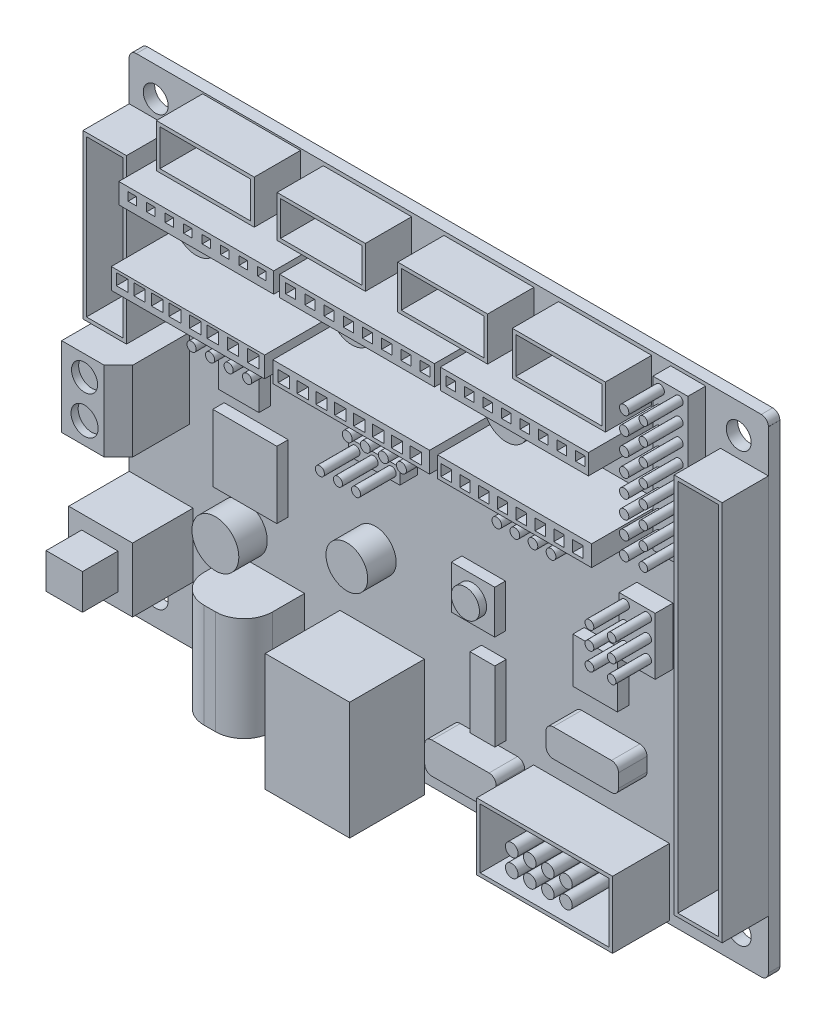
from build123d import *

# Parameters (mm, degrees)
BLACK_SMD_W             = 5.667528789
BLACK_SMD_H             = 6.353116949
BOSS_EXTRU_2_DEPTH      = 1.6
BLACK_SMD_W_2           = 9.004057835
BLACK_SMD_H_2           = 9.41541073
BOSS_EXTRU_2_2_DEPTH    = 1.6
BLACK_SMD_W_3           = 6.261705195
BOSS_EXTRU_2_3_DEPTH    = 1.6
BLACK_SMD_W_4           = 3.473646677
BLACK_SMD_H_3           = 9.872469503
BOSS_EXTRU_2_4_DEPTH    = 1.6
CAPA_CRYSTALS_R         = 3.185682442
BOSS_EXTRU_3_DEPTH      = 4
CAPA_CRYSTALS_R_2       = 3.107590138
BOSS_EXTRU_3_2_DEPTH    = 4
CAPA_CRYSTALS_R_3       = 3.145601867
BOSS_EXTRU_3_3_DEPTH    = 4
CAPA_CRYSTALS_R_4       = 2.932098197
BOSS_EXTRU_3_4_DEPTH    = 4
CAPA_CRYSTALS_R_5       = 3.296265694
BOSS_EXTRU_3_5_DEPTH    = 4
BOSS_EXTRU_3_6_DEPTH    = 4
BOSS_EXTRU_3_7_DEPTH    = 4
YELLOW_MALES_W          = 4.914957964
YELLOW_MALES_H          = 21.157358111
BOSS_EXTRU_4_DEPTH      = 2.5
YELLOW_MALES_W_2        = 5.072677352
YELLOW_MALES_H_2        = 8.037692987
BOSS_EXTRU_4_2_DEPTH    = 2.5
YELLOW_MALES_W_3        = 10.02137058
YELLOW_MALES_H_3        = 2.383305897
BOSS_EXTRU_4_3_DEPTH    = 2.5
YELLOW_MALES_W_4        = 9.80555218
BOSS_EXTRU_4_4_DEPTH    = 2.5
YELLOW_MALES_W_5        = 9.889772519
BOSS_EXTRU_4_5_DEPTH    = 2.5
YELLOW_MALES_W_6        = 7.186380027
YELLOW_MALES_H_4        = 2.19056063
BOSS_EXTRU_4_6_DEPTH    = 2.5
BLACKHEADERS_W          = 19.09327542
BLACKHEADERS_H          = 9.384830291
BOSS_EXTRU_5_DEPTH      = 8
BLUE_CONNECTOR_W        = 7.979000373
BLUE_CONNECTOR_H        = 11.177478971
BOSS_EXTRU_6_DEPTH      = 10
YELLOW_FEMALES_W        = 13.758897452
YELLOW_FEMALES_H        = 6.10412624
BOSS_EXTRU_7_DEPTH      = 6.5
YELLOW_FEMALES_W_2      = 12.405159778
YELLOW_FEMALES_H_2      = 5.833378705
BOSS_EXTRU_7_2_DEPTH    = 6.5
YELLOW_FEMALES_W_3      = 12.626680488
YELLOW_FEMALES_H_3      = 6.096742216
BOSS_EXTRU_7_3_DEPTH    = 6.5
YELLOW_FEMALES_W_4      = 13.079739121
BOSS_EXTRU_7_4_DEPTH    = 6.5
YELLOW_FEMALES_W_5      = 6.119428218
YELLOW_FEMALES_H_4      = 22.94160465
BOSS_EXTRU_7_5_DEPTH    = 6.5
YELLOW_FEMALES_W_6      = 6.736078406
YELLOW_FEMALES_H_5      = 53.569497278
BOSS_EXTRU_7_6_DEPTH    = 6.5
POWER12V_W              = 9.630174402
POWER12V_H              = 14.593768451
BOSS_EXTRU_8_DEPTH      = 8.5
USBPLUG_W               = 11.865628118
USBPLUG_H               = 16.535326927
BOSS_EXTRU_9_DEPTH      = 10.5
BUTTON_W                = 8.967148954
BUTTON_H                = 9.006388335
BOSS_EXTRU_10_DEPTH     = 8.5
RESET_W                 = 6.108615354
RESET_H                 = 6.080070422
BOSS_EXTRU_11_DEPTH     = 1.5
BOUTROUGE_R             = 1.981766693
BOSS_EXTRU_12_DEPTH     = 1
BOUTONON_W              = 5.108667304
BOUTONON_H              = 4.961772718
BOSS_EXTRU_13_DEPTH     = 5
CHANFREIN1_SIZE         = 2
CONG_1_R                = 4
ESQUISSE14_R            = 2.872316095
ENL_V_MAT_EXTRU_1_DEPTH = 10
ESQUISSE15_W            = 4.536879196
ESQUISSE15_H            = 2.837024223
ENL_V_MAT_EXTRU_2_DEPTH = 10
COQUE1_T                = -0.5
COQUE2_T                = -0.5
COQUE3_T                = -0.5
COQUE4_T                = -0.5
COQUE5_T                = -0.5
COQUE6_T                = -0.5
COQUE7_T                = -0.5
ESQUISSE16_R            = 1.832241223
ESQUISSE16_R_2          = 1.902205742
ENL_V_MAT_EXTRU_3_DEPTH = 1
CONNECTURES_JAUNES_W    = 21.766129974
CONNECTURES_JAUNES_H    = 2.845572038
CONNECTURES_JAUNES_W_2  = 1.144667962
CONNECTURES_JAUNES_H_2  = 1.160348345
BOSS_EXTRU_14_DEPTH     = 10
CONNECTURES_JAUNES_W_3  = 21.751237847
CONNECTURES_JAUNES_W_4  = 1.412281688
CONNECTURES_JAUNES_H_3  = 1.368226061
BOSS_EXTRU_14_2_DEPTH   = 10
CONNECTURES_JAUNES_W_5  = 20.809255106
CONNECTURES_JAUNES_W_6  = 1.305396378
CONNECTURES_JAUNES_H_4  = 1.311416644
BOSS_EXTRU_14_3_DEPTH   = 10
CONNECTEURS_NOIRS_W     = 21.542495223
CONNECTEURS_NOIRS_H     = 2.89995128
CONNECTEURS_NOIRS_W_2   = 1.623681217
CONNECTEURS_NOIRS_H_2   = 1.607525185
CONNECTEURS_NOIRS_W_3   = 1.591369153
CONNECTEURS_NOIRS_W_4   = 1.607525185
CONNECTEURS_NOIRS_W_5   = 1.679612214
CONNECTEURS_NOIRS_H_3   = 1.644637005
CONNECTEURS_NOIRS_W_6   = 1.594783313
CONNECTEURS_NOIRS_W_7   = 1.623059613
CONNECTEURS_NOIRS_W_8   = 1.570532536
CONNECTEURS_NOIRS_H_4   = 1.602694416
CONNECTEURS_NOIRS_W_9   = 1.616724668
CONNECTEURS_NOIRS_H_5   = 1.718717031
BOSS_EXTRU_15_DEPTH     = 10
CONNECTEURS_NOIRS_W_10  = 22.022715309
CONNECTEURS_NOIRS_W_11  = 1.593377301
CONNECTEURS_NOIRS_H_6   = 1.582156334
BOSS_EXTRU_15_2_DEPTH   = 10
CONNECTEURS_NOIRS_W_12  = 21.644304887
CONNECTEURS_NOIRS_W_13  = 1.447331161
BOSS_EXTRU_15_3_DEPTH   = 10
MALE_POINS_R            = 0.643851122
MALE_POINS_R_2          = 0.696264163
MALE_POINS_R_3          = 0.636731824
MALE_POINS_R_4          = 0.681329033
MALE_POINS_R_5          = 0.655895969
MALE_POINS_R_6          = 0.599442367
MALE_POINS_R_7          = 0.619190014
MALE_POINS_R_8          = 0.60345103
BOSS_EXTRU_16_DEPTH     = 5
ESQUISSE20_R            = 0.886471356
BOSS_EXTRU_17_DEPTH     = 8
ESQUISSE1_R             = 1.75
BOSS_EXTRU_18_DEPTH     = 1.6
ESQUISSE21_W            = 1.6
ESQUISSE21_H            = 66.466866995
BOSS_EXTRU_19_DEPTH     = 0.01
ESQUISSE22_W            = 1.6
ESQUISSE22_H            = 66.466866995
BOSS_EXTRU_20_DEPTH     = 0.01


with BuildPart() as part:
    # black smd → Boss.-Extru.2 (new body)
    with BuildSketch(Plane.XY):
        with Locations((27.451835352, 92.668727708)):
            Rectangle(BLACK_SMD_W, BLACK_SMD_H)
    extrude(amount=BOSS_EXTRU_2_DEPTH)



with BuildPart() as body_2:
    # black smd → Boss.-Extru.2 2 (new body)
    with BuildSketch(Plane.XY):
        with Locations((28.297394083, 81.950699473)):
            Rectangle(BLACK_SMD_W_2, BLACK_SMD_H_2)
    extrude(amount=BOSS_EXTRU_2_2_DEPTH)


with BuildPart() as body_3:
    # black smd → Boss.-Extru.2 3 (new body)
    with BuildSketch(Plane.XY):
        with Locations((77.522623968, 81.425081884)):
            Rectangle(BLACK_SMD_W_3, BLACK_SMD_H)
    extrude(amount=BOSS_EXTRU_2_3_DEPTH)


with BuildPart() as body_4:
    # black smd → Boss.-Extru.2 4 (new body)
    with BuildSketch(Plane.XY):
        with Locations((61.685537474, 70.295700754)):
            Rectangle(BLACK_SMD_W_4, BLACK_SMD_H_3)
    extrude(amount=BOSS_EXTRU_2_4_DEPTH)


with BuildPart() as body_5:
    # capa-crystals → Boss.-Extru.3 (new body)
    with BuildSketch(Plane.XY):
        with Locations((23.864549463, 109.798281788)):
            Circle(CAPA_CRYSTALS_R)
    extrude(amount=BOSS_EXTRU_3_DEPTH)


with BuildPart() as body_6:
    # capa-crystals → Boss.-Extru.3 2 (new body)
    with BuildSketch(Plane.XY):
        with Locations((45.731701556, 109.764509907)):
            Circle(CAPA_CRYSTALS_R_2)
    extrude(amount=BOSS_EXTRU_3_2_DEPTH)


with BuildPart() as body_7:
    # capa-crystals → Boss.-Extru.3 3 (new body)
    with BuildSketch(Plane.XY):
        with Locations((67.426141208, 108.850187956)):
            Circle(CAPA_CRYSTALS_R_3)
    extrude(amount=BOSS_EXTRU_3_3_DEPTH)


with BuildPart() as body_8:
    # capa-crystals → Boss.-Extru.3 4 (new body)
    with BuildSketch(Plane.XY):
        with Locations((45.03448566, 79.310789046)):
            Circle(CAPA_CRYSTALS_R_4)
    extrude(amount=BOSS_EXTRU_3_4_DEPTH)


with BuildPart() as body_9:
    # capa-crystals → Boss.-Extru.3 5 (new body)
    with BuildSketch(Plane.XY):
        with Locations((26.561536765, 72.880879708)):
            Circle(CAPA_CRYSTALS_R_5)
    extrude(amount=BOSS_EXTRU_3_5_DEPTH)


with BuildPart() as body_10:
    # capa-crystals → Boss.-Extru.3 6 (new body)
    with BuildSketch(Plane.XY):
        with BuildLine():
            Line((74.029880501, 74.337328349), (82.213679809, 74.337328349))
            ThreePointArc((82.213679809, 74.337328349), (82.92078659, 74.04443513), (83.213679809, 73.337328349))
            Line((83.213679809, 73.337328349), (83.213679809, 71.430452614))
            ThreePointArc((83.213679809, 71.430452614), (82.92078659, 70.723345833), (82.213679809, 70.430452614))
            Line((82.213679809, 70.430452614), (74.029880501, 70.430452614))
            ThreePointArc((74.029880501, 70.430452614), (73.32277372, 70.723345833), (73.029880501, 71.430452614))
            Line((73.029880501, 71.430452614), (73.029880501, 73.337328349))
            ThreePointArc((73.029880501, 73.337328349), (73.32277372, 74.04443513), (74.029880501, 74.337328349))
        make_face()
    extrude(amount=BOSS_EXTRU_3_6_DEPTH)


with BuildPart() as body_11:
    # capa-crystals → Boss.-Extru.3 7 (new body)
    with BuildSketch(Plane.XY):
        with BuildLine():
            Line((56.976645659, 64.209077037), (65.012316977, 64.209077037))
            ThreePointArc((65.012316977, 64.209077037), (65.719423758, 63.916183818), (66.012316977, 63.209077037))
            Line((66.012316977, 63.209077037), (66.012316977, 60.802269336))
            ThreePointArc((66.012316977, 60.802269336), (65.719423758, 60.095162555), (65.012316977, 59.802269336))
            Line((65.012316977, 59.802269336), (56.976645659, 59.802269336))
            ThreePointArc((56.976645659, 59.802269336), (56.269538877, 60.095162555), (55.976645659, 60.802269336))
            Line((55.976645659, 60.802269336), (55.976645659, 63.209077037))
            ThreePointArc((55.976645659, 63.209077037), (56.269538877, 63.916183818), (56.976645659, 64.209077037))
        make_face()
    extrude(amount=BOSS_EXTRU_3_7_DEPTH)


with BuildPart() as body_12:
    # yellow males → Boss.-Extru.4 (new body)
    with BuildSketch(Plane.XY):
        with Locations((88.999549893, 111.93581949)):
            Rectangle(YELLOW_MALES_W, YELLOW_MALES_H)
    extrude(amount=BOSS_EXTRU_4_DEPTH)



with BuildPart() as body_13:
    # yellow males → Boss.-Extru.4 2 (new body)
    with BuildSketch(Plane.XY):
        with Locations((84.324792683, 89.789654597)):
            Rectangle(YELLOW_MALES_W_2, YELLOW_MALES_H_2)
    extrude(amount=BOSS_EXTRU_4_2_DEPTH)


with BuildPart() as body_14:
    # yellow males → Boss.-Extru.4 3 (new body)
    with BuildSketch(Plane.XY):
        with Locations((30.694945941, 98.746631162)):
            Rectangle(YELLOW_MALES_W_3, YELLOW_MALES_H_3)
    extrude(amount=BOSS_EXTRU_4_3_DEPTH)


with BuildPart() as body_15:
    # yellow males → Boss.-Extru.4 4 (new body)
    with BuildSketch(Plane.XY):
        with Locations((52.352649633, 98.746631162)):
            Rectangle(YELLOW_MALES_W_4, YELLOW_MALES_H_3)
    extrude(amount=BOSS_EXTRU_4_4_DEPTH)


with BuildPart() as body_16:
    # yellow males → Boss.-Extru.4 5 (new body)
    with BuildSketch(Plane.XY):
        with Locations((73.557762357, 98.746631162)):
            Rectangle(YELLOW_MALES_W_5, YELLOW_MALES_H_3)
    extrude(amount=BOSS_EXTRU_4_5_DEPTH)


with BuildPart() as body_17:
    # yellow males → Boss.-Extru.4 6 (new body)
    with BuildSketch(Plane.XY):
        with Locations((47.382493908, 92.554802146)):
            Rectangle(YELLOW_MALES_W_6, YELLOW_MALES_H_4)
    extrude(amount=BOSS_EXTRU_4_6_DEPTH)


with BuildPart() as body_18:
    # blackheaders → Boss.-Extru.5 (new body)
    with BuildSketch(Plane.XY):
        with Locations((76.827722943, 59.625791726)):
            Rectangle(BLACKHEADERS_W, BLACKHEADERS_H)
    extrude(amount=BOSS_EXTRU_5_DEPTH)

    # Coque6
    coque6_openings = [body_18.faces().sort_by_distance(p)[0] for p in [
        (76.827722943, 59.625791725, 8),
    ]]
    offset(amount=COQUE6_T, openings=coque6_openings, kind=Kind.INTERSECTION)

    # Esquisse20 → Boss.-Extru.17 (add)
    with BuildSketch(Plane(origin=(1.991400951, -0.772175879, 0.5), x_dir=(1, 0, 0), z_dir=(0, 0, 1))):
        with Locations((70.711902777, 61.723200827)):
            Circle(ESQUISSE20_R)
        with Locations((73.251902777, 61.723200827)):
            Circle(ESQUISSE20_R)
        with Locations((75.791902777, 61.723200827)):
            Circle(ESQUISSE20_R)
        with Locations((78.331902777, 61.723200827)):
            Circle(ESQUISSE20_R)
        with Locations((73.251902777, 59.183200827)):
            Circle(ESQUISSE20_R)
        with Locations((75.791902777, 59.183200827)):
            Circle(ESQUISSE20_R)
        with Locations((78.331902777, 59.183200827)):
            Circle(ESQUISSE20_R)
        with Locations((70.711902777, 59.183200827)):
            Circle(ESQUISSE20_R)
    extrude(amount=BOSS_EXTRU_17_DEPTH)


with BuildPart() as body_19:
    # blue connector → Boss.-Extru.6 (new body)
    with BuildSketch(Plane.XY):
        with Locations((14.954034151, 87.207277797)):
            Rectangle(BLUE_CONNECTOR_W, BLUE_CONNECTOR_H)
    extrude(amount=BOSS_EXTRU_6_DEPTH)

    # Chanfrein1
    chanfrein1_edges = [body_19.edges().sort_by_distance(p)[0] for p in [
        (18.943534337, 87.207277796, 10),
    ]]
    chamfer(chanfrein1_edges, length=CHANFREIN1_SIZE)

    # Esquisse16 → Enlèv. mat.-Extru.3 (cut)
    with BuildSketch(Plane.XY.offset(10)):
        with Locations((14.182289889, 89.945307425)):
            Circle(ESQUISSE16_R)
        with Locations((14.182289889, 84.657102292)):
            Circle(ESQUISSE16_R_2)
    extrude(amount=-ENL_V_MAT_EXTRU_3_DEPTH, mode=Mode.SUBTRACT)


with BuildPart() as body_20:
    # yellow females → Boss.-Extru.7 (new body)
    with BuildSketch(Plane.XY):
        with Locations((27.650264608, 119.67670561)):
            Rectangle(YELLOW_FEMALES_W, YELLOW_FEMALES_H)
    extrude(amount=BOSS_EXTRU_7_DEPTH)

    # Coque1
    coque1_openings = [body_20.faces().sort_by_distance(p)[0] for p in [
        (27.650264608, 119.67670561, 6.5),
    ]]
    offset(amount=COQUE1_T, openings=coque1_openings, kind=Kind.INTERSECTION)


with BuildPart() as body_21:
    # yellow females → Boss.-Extru.7 2 (new body)
    with BuildSketch(Plane.XY):
        with Locations((43.932036817, 119.541331842)):
            Rectangle(YELLOW_FEMALES_W_2, YELLOW_FEMALES_H_2)
    extrude(amount=BOSS_EXTRU_7_2_DEPTH)

    # Coque2
    coque2_openings = [body_21.faces().sort_by_distance(p)[0] for p in [
        (43.932036817, 119.541331842, 6.5),
    ]]
    offset(amount=COQUE2_T, openings=coque2_openings, kind=Kind.INTERSECTION)


with BuildPart() as body_22:
    # yellow females → Boss.-Extru.7 3 (new body)
    with BuildSketch(Plane.XY):
        with Locations((61.001438217, 119.409650087)):
            Rectangle(YELLOW_FEMALES_W_3, YELLOW_FEMALES_H_3)
    extrude(amount=BOSS_EXTRU_7_3_DEPTH)

    # Coque3
    coque3_openings = [body_22.faces().sort_by_distance(p)[0] for p in [
        (61.001438217, 119.409650087, 6.5),
    ]]
    offset(amount=COQUE3_T, openings=coque3_openings, kind=Kind.INTERSECTION)


with BuildPart() as body_23:
    # yellow females → Boss.-Extru.7 4 (new body)
    with BuildSketch(Plane.XY):
        with Locations((77.324717378, 119.409650087)):
            Rectangle(YELLOW_FEMALES_W_4, YELLOW_FEMALES_H_3)
    extrude(amount=BOSS_EXTRU_7_4_DEPTH)

    # Coque4
    coque4_openings = [body_23.faces().sort_by_distance(p)[0] for p in [
        (77.324717378, 119.409650087, 6.5),
    ]]
    offset(amount=COQUE4_T, openings=coque4_openings, kind=Kind.INTERSECTION)


with BuildPart() as body_24:
    # yellow females → Boss.-Extru.7 5 (new body)
    with BuildSketch(Plane.XY):
        with Locations((13.512656055, 104.890476654)):
            Rectangle(YELLOW_FEMALES_W_5, YELLOW_FEMALES_H_4)
    extrude(amount=BOSS_EXTRU_7_5_DEPTH)

    # Coque7
    coque7_openings = [body_24.faces().sort_by_distance(p)[0] for p in [
        (13.512656055, 104.890476654, 6.5),
    ]]
    offset(amount=COQUE7_T, openings=coque7_openings, kind=Kind.INTERSECTION)


with BuildPart() as body_25:
    # yellow females → Boss.-Extru.7 6 (new body)
    with BuildSketch(Plane.XY):
        with Locations((96.907395701, 89.199249655)):
            Rectangle(YELLOW_FEMALES_W_6, YELLOW_FEMALES_H_5)
    extrude(amount=BOSS_EXTRU_7_6_DEPTH)

    # Coque5
    coque5_openings = [body_25.faces().sort_by_distance(p)[0] for p in [
        (96.907395701, 89.199249655, 6.5),
    ]]
    offset(amount=COQUE5_T, openings=coque5_openings, kind=Kind.INTERSECTION)


with BuildPart() as body_26:
    # power12v → Boss.-Extru.8 (new body)
    with BuildSketch(Plane.XY):
        with Locations((30.282665386, 61.805056702)):
            Rectangle(POWER12V_W, POWER12V_H)
    extrude(amount=BOSS_EXTRU_8_DEPTH)

    # Congé1
    cong_1_edges = [body_26.edges().sort_by_distance(p)[0] for p in [
        (35.097752587, 61.805056702, 8.5),
        (25.467578185, 61.805056702, 8.5),
    ]]
    fillet(cong_1_edges, radius=CONG_1_R)

    # Esquisse14 → Enlèv. mat.-Extru.1 (cut)
    with BuildSketch(Plane.XZ.offset(-54.508172476)):
        with Locations((30.340408276, 4.608223464)):
            Circle(ESQUISSE14_R)
    extrude(amount=-ENL_V_MAT_EXTRU_1_DEPTH, mode=Mode.SUBTRACT)


with BuildPart() as body_27:
    # usbplug → Boss.-Extru.9 (new body)
    with BuildSketch(Plane.XY):
        with Locations((45.998146307, 61.256418237)):
            Rectangle(USBPLUG_W, USBPLUG_H)
    extrude(amount=BOSS_EXTRU_9_DEPTH)

    # Esquisse15 → Enlèv. mat.-Extru.2 (cut)
    with BuildSketch(Plane.XZ.offset(-52.988754773)):
        Polygon((43.681261857, 8.05866864), (48.218141053, 8.05866864), (50.533256363, 6.303661872), (50.533256363, 1.785452961), (41.683541388, 1.785452961), (41.683541388, 6.378343012), align=None)
        with Locations((45.949701455, 4.959830901)):
            Rectangle(ESQUISSE15_W, ESQUISSE15_H, mode=Mode.SUBTRACT)
    extrude(amount=-ENL_V_MAT_EXTRU_2_DEPTH, mode=Mode.SUBTRACT)


with BuildPart() as body_28:
    # button → Boss.-Extru.10 (new body)
    with BuildSketch(Plane.XY):
        with Locations((14.936516423, 67.138871687)):
            Rectangle(BUTTON_W, BUTTON_H)
    extrude(amount=BOSS_EXTRU_10_DEPTH)

    # boutonon → Boss.-Extru.13 (add)
    with BuildSketch(Plane.XY.offset(8.5)):
        with Locations((14.832436998, 67.17090773)):
            Rectangle(BOUTONON_W, BOUTONON_H)
    extrude(amount=BOSS_EXTRU_13_DEPTH)


with BuildPart() as body_29:
    # reset → Boss.-Extru.11 (new body)
    with BuildSketch(Plane.XY):
        with Locations((60.264292003, 81.67716215)):
            Rectangle(RESET_W, RESET_H)
    extrude(amount=BOSS_EXTRU_11_DEPTH)

    # boutrouge → Boss.-Extru.12 (add)
    with BuildSketch(Plane.XY.offset(1.5)):
        with Locations((60.191949439, 81.715872772)):
            Circle(BOUTROUGE_R)
    extrude(amount=BOSS_EXTRU_12_DEPTH)


with BuildPart() as body_30:
    # connectures jaunes → Boss.-Extru.14 (new body)
    with BuildSketch(Plane.XY):
        with Locations((29.874433173, 114.758711057)):
            Rectangle(CONNECTURES_JAUNES_W, CONNECTURES_JAUNES_H)
        with Locations((23.473914496, 115.011223112)):
            Rectangle(CONNECTURES_JAUNES_W_2, CONNECTURES_JAUNES_H_2, mode=Mode.SUBTRACT)
        with Locations((20.873914496, 115.011223112)):
            Rectangle(CONNECTURES_JAUNES_W_2, CONNECTURES_JAUNES_H_2, mode=Mode.SUBTRACT)
        with Locations((26.073914496, 115.011223112)):
            Rectangle(CONNECTURES_JAUNES_W_2, CONNECTURES_JAUNES_H_2, mode=Mode.SUBTRACT)
        with Locations((28.673914496, 115.011223112)):
            Rectangle(CONNECTURES_JAUNES_W_2, CONNECTURES_JAUNES_H_2, mode=Mode.SUBTRACT)
        with Locations((31.273914496, 115.011223112)):
            Rectangle(CONNECTURES_JAUNES_W_2, CONNECTURES_JAUNES_H_2, mode=Mode.SUBTRACT)
        with Locations((33.873914496, 115.011223112)):
            Rectangle(CONNECTURES_JAUNES_W_2, CONNECTURES_JAUNES_H_2, mode=Mode.SUBTRACT)
        with Locations((36.473914496, 115.011223112)):
            Rectangle(CONNECTURES_JAUNES_W_2, CONNECTURES_JAUNES_H_2, mode=Mode.SUBTRACT)
        with Locations((39.073914496, 115.011223112)):
            Rectangle(CONNECTURES_JAUNES_W_2, CONNECTURES_JAUNES_H_2, mode=Mode.SUBTRACT)
    extrude(amount=BOSS_EXTRU_14_DEPTH)


with BuildPart() as body_31:
    # connectures jaunes → Boss.-Extru.14 2 (new body)
    with BuildSketch(Plane.XY):
        with Locations((52.467013892, 114.758711057)):
            Rectangle(CONNECTURES_JAUNES_W_3, CONNECTURES_JAUNES_H)
        with Locations((45.840802128, 114.907284254)):
            Rectangle(CONNECTURES_JAUNES_W_4, CONNECTURES_JAUNES_H_3, mode=Mode.SUBTRACT)
        with Locations((43.140802128, 114.907284254)):
            Rectangle(CONNECTURES_JAUNES_W_4, CONNECTURES_JAUNES_H_3, mode=Mode.SUBTRACT)
        with Locations((48.540802128, 114.907284254)):
            Rectangle(CONNECTURES_JAUNES_W_4, CONNECTURES_JAUNES_H_3, mode=Mode.SUBTRACT)
        with Locations((51.240802128, 114.907284254)):
            Rectangle(CONNECTURES_JAUNES_W_4, CONNECTURES_JAUNES_H_3, mode=Mode.SUBTRACT)
        with Locations((53.940802128, 114.907284254)):
            Rectangle(CONNECTURES_JAUNES_W_4, CONNECTURES_JAUNES_H_3, mode=Mode.SUBTRACT)
        with Locations((56.640802128, 114.907284254)):
            Rectangle(CONNECTURES_JAUNES_W_4, CONNECTURES_JAUNES_H_3, mode=Mode.SUBTRACT)
        with Locations((59.340802128, 114.907284254)):
            Rectangle(CONNECTURES_JAUNES_W_4, CONNECTURES_JAUNES_H_3, mode=Mode.SUBTRACT)
        with Locations((62.040802128, 114.907284254)):
            Rectangle(CONNECTURES_JAUNES_W_4, CONNECTURES_JAUNES_H_3, mode=Mode.SUBTRACT)
    extrude(amount=BOSS_EXTRU_14_2_DEPTH)


with BuildPart() as body_32:
    # connectures jaunes → Boss.-Extru.14 3 (new body)
    with BuildSketch(Plane.XY):
        with Locations((74.575063383, 114.758711057)):
            Rectangle(CONNECTURES_JAUNES_W_5, CONNECTURES_JAUNES_H)
        with Locations((68.231383082, 114.878879545)):
            Rectangle(CONNECTURES_JAUNES_W_6, CONNECTURES_JAUNES_H_4, mode=Mode.SUBTRACT)
        with Locations((65.631383082, 114.878879545)):
            Rectangle(CONNECTURES_JAUNES_W_6, CONNECTURES_JAUNES_H_4, mode=Mode.SUBTRACT)
        with Locations((70.831383082, 114.878879545)):
            Rectangle(CONNECTURES_JAUNES_W_6, CONNECTURES_JAUNES_H_4, mode=Mode.SUBTRACT)
        with Locations((73.431383082, 114.878879545)):
            Rectangle(CONNECTURES_JAUNES_W_6, CONNECTURES_JAUNES_H_4, mode=Mode.SUBTRACT)
        with Locations((76.031383082, 114.878879545)):
            Rectangle(CONNECTURES_JAUNES_W_6, CONNECTURES_JAUNES_H_4, mode=Mode.SUBTRACT)
        with Locations((78.631383082, 114.878879545)):
            Rectangle(CONNECTURES_JAUNES_W_6, CONNECTURES_JAUNES_H_4, mode=Mode.SUBTRACT)
        with Locations((81.231383082, 114.878879545)):
            Rectangle(CONNECTURES_JAUNES_W_6, CONNECTURES_JAUNES_H_4, mode=Mode.SUBTRACT)
        with Locations((83.831383082, 114.878879545)):
            Rectangle(CONNECTURES_JAUNES_W_6, CONNECTURES_JAUNES_H_4, mode=Mode.SUBTRACT)
    extrude(amount=BOSS_EXTRU_14_3_DEPTH)


with BuildPart() as body_33:
    # connecteurs noirs → Boss.-Extru.15 (new body)
    with BuildSketch(Plane.XY):
        with Locations((28.706780425, 103.852734119)):
            Rectangle(CONNECTEURS_NOIRS_W, CONNECTEURS_NOIRS_H)
        with Locations((19.459783137, 104.119588936)):
            Rectangle(CONNECTEURS_NOIRS_W_2, CONNECTEURS_NOIRS_H_2, mode=Mode.SUBTRACT)
        with Locations((21.907421986, 104.119588936)):
            Rectangle(CONNECTEURS_NOIRS_W_3, CONNECTEURS_NOIRS_H_2, mode=Mode.SUBTRACT)
        with Locations((24.387372899, 104.119588936)):
            Rectangle(CONNECTEURS_NOIRS_W_4, CONNECTEURS_NOIRS_H_2, mode=Mode.SUBTRACT)
        with Locations((26.880477214, 104.101033026)):
            Rectangle(CONNECTEURS_NOIRS_W_5, CONNECTEURS_NOIRS_H_3, mode=Mode.SUBTRACT)
        with Locations((29.727900613, 104.101033026)):
            Rectangle(CONNECTEURS_NOIRS_W_6, CONNECTEURS_NOIRS_H_3, mode=Mode.SUBTRACT)
        with Locations((32.219042633, 104.101033026)):
            Rectangle(CONNECTEURS_NOIRS_W_7, CONNECTEURS_NOIRS_H_3, mode=Mode.SUBTRACT)
        with Locations((35.041216176, 104.080061731)):
            Rectangle(CONNECTEURS_NOIRS_W_8, CONNECTEURS_NOIRS_H_4, mode=Mode.SUBTRACT)
        with Locations((37.914366873, 104.063993013)):
            Rectangle(CONNECTEURS_NOIRS_W_9, CONNECTEURS_NOIRS_H_5, mode=Mode.SUBTRACT)
    extrude(amount=BOSS_EXTRU_15_DEPTH)


with BuildPart() as body_34:
    # connecteurs noirs → Boss.-Extru.15 2 (new body)
    with BuildSketch(Plane.XY):
        with Locations((51.652552963, 103.852734119)):
            Rectangle(CONNECTEURS_NOIRS_W_10, CONNECTEURS_NOIRS_H)
        with Locations((44.831593433, 103.697294106)):
            Rectangle(CONNECTEURS_NOIRS_W_11, CONNECTEURS_NOIRS_H_6, mode=Mode.SUBTRACT)
        with Locations((42.181593433, 103.697294106)):
            Rectangle(CONNECTEURS_NOIRS_W_11, CONNECTEURS_NOIRS_H_6, mode=Mode.SUBTRACT)
        with Locations((47.481593433, 103.697294106)):
            Rectangle(CONNECTEURS_NOIRS_W_11, CONNECTEURS_NOIRS_H_6, mode=Mode.SUBTRACT)
        with Locations((50.131593433, 103.697294106)):
            Rectangle(CONNECTEURS_NOIRS_W_11, CONNECTEURS_NOIRS_H_6, mode=Mode.SUBTRACT)
        with Locations((52.781593433, 103.697294106)):
            Rectangle(CONNECTEURS_NOIRS_W_11, CONNECTEURS_NOIRS_H_6, mode=Mode.SUBTRACT)
        with Locations((55.431593433, 103.697294106)):
            Rectangle(CONNECTEURS_NOIRS_W_11, CONNECTEURS_NOIRS_H_6, mode=Mode.SUBTRACT)
        with Locations((58.081593433, 103.697294106)):
            Rectangle(CONNECTEURS_NOIRS_W_11, CONNECTEURS_NOIRS_H_6, mode=Mode.SUBTRACT)
        with Locations((60.731593433, 103.697294106)):
            Rectangle(CONNECTEURS_NOIRS_W_11, CONNECTEURS_NOIRS_H_6, mode=Mode.SUBTRACT)
    extrude(amount=BOSS_EXTRU_15_2_DEPTH)


with BuildPart() as body_35:
    # connecteurs noirs → Boss.-Extru.15 3 (new body)
    with BuildSketch(Plane.XY):
        with Locations((74.610534689, 103.852734119)):
            Rectangle(CONNECTEURS_NOIRS_W_12, CONNECTEURS_NOIRS_H)
        with Locations((67.633122554, 103.697294106)):
            Rectangle(CONNECTEURS_NOIRS_W_13, CONNECTEURS_NOIRS_H_6, mode=Mode.SUBTRACT)
        with Locations((64.993122554, 103.697294106)):
            Rectangle(CONNECTEURS_NOIRS_W_13, CONNECTEURS_NOIRS_H_6, mode=Mode.SUBTRACT)
        with Locations((70.273122554, 103.697294106)):
            Rectangle(CONNECTEURS_NOIRS_W_13, CONNECTEURS_NOIRS_H_6, mode=Mode.SUBTRACT)
        with Locations((72.913122554, 103.697294106)):
            Rectangle(CONNECTEURS_NOIRS_W_13, CONNECTEURS_NOIRS_H_6, mode=Mode.SUBTRACT)
        with Locations((75.553122554, 103.697294106)):
            Rectangle(CONNECTEURS_NOIRS_W_13, CONNECTEURS_NOIRS_H_6, mode=Mode.SUBTRACT)
        with Locations((78.193122554, 103.697294106)):
            Rectangle(CONNECTEURS_NOIRS_W_13, CONNECTEURS_NOIRS_H_6, mode=Mode.SUBTRACT)
        with Locations((80.833122554, 103.697294106)):
            Rectangle(CONNECTEURS_NOIRS_W_13, CONNECTEURS_NOIRS_H_6, mode=Mode.SUBTRACT)
        with Locations((83.473122554, 103.697294106)):
            Rectangle(CONNECTEURS_NOIRS_W_13, CONNECTEURS_NOIRS_H_6, mode=Mode.SUBTRACT)
    extrude(amount=BOSS_EXTRU_15_3_DEPTH)


with BuildPart() as body_12_1:
    add(body_12.part)

    add(body_13.part)  # Boss.-Extru.16 merges body 13

    add(body_14.part)  # Boss.-Extru.16 merges body 14

    add(body_15.part)  # Boss.-Extru.16 merges body 15

    add(body_16.part)  # Boss.-Extru.16 merges body 16

    add(body_17.part)  # Boss.-Extru.16 merges body 17
    # male poins → Boss.-Extru.16 (add)
    with BuildSketch(Plane.XY.offset(2.5)):
        with Locations((26.719544477, 98.693322474)):
            Circle(MALE_POINS_R)
        with Locations((29.319544477, 98.693322474)):
            Circle(MALE_POINS_R)
        with Locations((31.919544477, 98.693322474)):
            Circle(MALE_POINS_R)
        with Locations((34.519544477, 98.693322474)):
            Circle(MALE_POINS_R)
        with Locations((48.586815237, 98.693322474)):
            Circle(MALE_POINS_R_2)
        with Locations((51.126815237, 98.693322474)):
            Circle(MALE_POINS_R_2)
        with Locations((53.666815237, 98.693322474)):
            Circle(MALE_POINS_R_2)
        with Locations((56.206815237, 98.693322474)):
            Circle(MALE_POINS_R_2)
        with Locations((44.744913159, 92.563954772)):
            Circle(MALE_POINS_R_3)
        with Locations((47.284913159, 92.563954772)):
            Circle(MALE_POINS_R_3)
        with Locations((49.824913159, 92.563954772)):
            Circle(MALE_POINS_R_3)
        with Locations((69.60442474, 98.693322474)):
            Circle(MALE_POINS_R_4)
        with Locations((72.14442474, 98.693322474)):
            Circle(MALE_POINS_R_4)
        with Locations((74.68442474, 98.693322474)):
            Circle(MALE_POINS_R_4)
        with Locations((77.22442474, 98.693322474)):
            Circle(MALE_POINS_R_4)
        with Locations((87.499189527, 121.387788101)):
            Circle(MALE_POINS_R_5)
        with Locations((90.193408354, 121.387788101)):
            Circle(MALE_POINS_R_6)
        with Locations((90.193408354, 118.847788101)):
            Circle(MALE_POINS_R_6)
        with Locations((87.499189527, 118.847788101)):
            Circle(MALE_POINS_R_5)
        with Locations((90.193408354, 116.307788101)):
            Circle(MALE_POINS_R_6)
        with Locations((87.499189527, 116.307788101)):
            Circle(MALE_POINS_R_5)
        with Locations((90.193408354, 113.767788101)):
            Circle(MALE_POINS_R_6)
        with Locations((87.499189527, 113.767788101)):
            Circle(MALE_POINS_R_5)
        with Locations((90.193408354, 111.227788101)):
            Circle(MALE_POINS_R_6)
        with Locations((87.499189527, 111.227788101)):
            Circle(MALE_POINS_R_5)
        with Locations((90.193408354, 108.687788101)):
            Circle(MALE_POINS_R_6)
        with Locations((87.499189527, 108.687788101)):
            Circle(MALE_POINS_R_5)
        with Locations((90.193408354, 106.147788101)):
            Circle(MALE_POINS_R_6)
        with Locations((87.499189527, 106.147788101)):
            Circle(MALE_POINS_R_5)
        with Locations((90.193408354, 103.607788101)):
            Circle(MALE_POINS_R_6)
        with Locations((87.499189527, 103.607788101)):
            Circle(MALE_POINS_R_5)
        with Locations((82.621038556, 92.797612021)):
            Circle(MALE_POINS_R_7)
        with Locations((85.740353282, 92.797612021)):
            Circle(MALE_POINS_R_8)
        with Locations((85.740353282, 90.257612021)):
            Circle(MALE_POINS_R_8)
        with Locations((82.621038556, 90.257612021)):
            Circle(MALE_POINS_R_7)
        with Locations((85.740353282, 87.717612021)):
            Circle(MALE_POINS_R_8)
        with Locations((82.621038556, 87.717612021)):
            Circle(MALE_POINS_R_7)
    extrude(amount=BOSS_EXTRU_16_DEPTH)


with BuildPart() as part_1:
    add(part.part)

    add(body_2.part)  # Boss.-Extru.18 merges body 2

    add(body_3.part)  # Boss.-Extru.18 merges body 3

    add(body_4.part)  # Boss.-Extru.18 merges body 4

    add(body_5.part)  # Boss.-Extru.18 merges body 5

    add(body_6.part)  # Boss.-Extru.18 merges body 6

    add(body_7.part)  # Boss.-Extru.18 merges body 7

    add(body_8.part)  # Boss.-Extru.18 merges body 8

    add(body_9.part)  # Boss.-Extru.18 merges body 9

    add(body_10.part)  # Boss.-Extru.18 merges body 10

    add(body_11.part)  # Boss.-Extru.18 merges body 11

    add(body_12_1.part)  # Boss.-Extru.18 merges body 12

    add(body_18.part)  # Boss.-Extru.18 merges body 18

    add(body_19.part)  # Boss.-Extru.18 merges body 19

    add(body_20.part)  # Boss.-Extru.18 merges body 20

    add(body_21.part)  # Boss.-Extru.18 merges body 21

    add(body_22.part)  # Boss.-Extru.18 merges body 22

    add(body_23.part)  # Boss.-Extru.18 merges body 23

    add(body_24.part)  # Boss.-Extru.18 merges body 24

    add(body_25.part)  # Boss.-Extru.18 merges body 25

    add(body_26.part)  # Boss.-Extru.18 merges body 26

    add(body_27.part)  # Boss.-Extru.18 merges body 27

    add(body_28.part)  # Boss.-Extru.18 merges body 28

    add(body_29.part)  # Boss.-Extru.18 merges body 29

    add(body_30.part)  # Boss.-Extru.18 merges body 30

    add(body_31.part)  # Boss.-Extru.18 merges body 31

    add(body_32.part)  # Boss.-Extru.18 merges body 32

    add(body_33.part)  # Boss.-Extru.18 merges body 33

    add(body_34.part)  # Boss.-Extru.18 merges body 34

    add(body_35.part)  # Boss.-Extru.18 merges body 35
    # Esquisse1 → Boss.-Extru.18 (add)
    with BuildSketch(Plane.XY):
        with BuildLine():
            Line((99.275434904, 54.508172476), (11.452941946, 54.508172476))
            ThreePointArc((11.452941946, 54.508172476), (10.745835164, 54.801065695), (10.452941946, 55.508172476))
            Line((10.452941946, 55.508172476), (10.452941946, 121.975039471))
            ThreePointArc((10.452941946, 121.975039471), (10.745835164, 122.682146253), (11.452941946, 122.975039471))
            Line((11.452941946, 122.975039471), (99.275434904, 122.975039471))
            ThreePointArc((99.275434904, 122.975039471), (99.982541685, 122.682146253), (100.275434904, 121.975039471))
            Line((100.275434904, 121.975039471), (100.275434904, 55.508172476))
            ThreePointArc((100.275434904, 55.508172476), (99.982541685, 54.801065695), (99.275434904, 54.508172476))
        make_face()
        with Locations((14.182289889, 118.822214927)):
            Circle(ESQUISSE1_R, mode=Mode.SUBTRACT)
        with Locations((96.103577218, 118.822214927)):
            Circle(ESQUISSE1_R, mode=Mode.SUBTRACT)
        with Locations((14.182289889, 58.588154251)):
            Circle(ESQUISSE1_R, mode=Mode.SUBTRACT)
        with Locations((96.103577218, 58.588154251)):
            Circle(ESQUISSE1_R, mode=Mode.SUBTRACT)
    extrude(amount=-BOSS_EXTRU_18_DEPTH)

    # Esquisse21 → Boss.-Extru.19 (add)
    with BuildSketch(Plane.ZY.offset(-10.452941946)):
        with Locations((-0.8, 88.741605974)):
            Rectangle(ESQUISSE21_W, ESQUISSE21_H)
    extrude(amount=BOSS_EXTRU_19_DEPTH)

    # Esquisse22 → Boss.-Extru.20 (add)
    with BuildSketch(Plane(origin=(100.275434904, 0, 0), x_dir=(0, 0, -1), z_dir=(1, 0, 0))):
        with Locations((0.8, 88.741605974)):
            Rectangle(ESQUISSE22_W, ESQUISSE22_H)
    extrude(amount=BOSS_EXTRU_20_DEPTH)


solid = part_1.part
